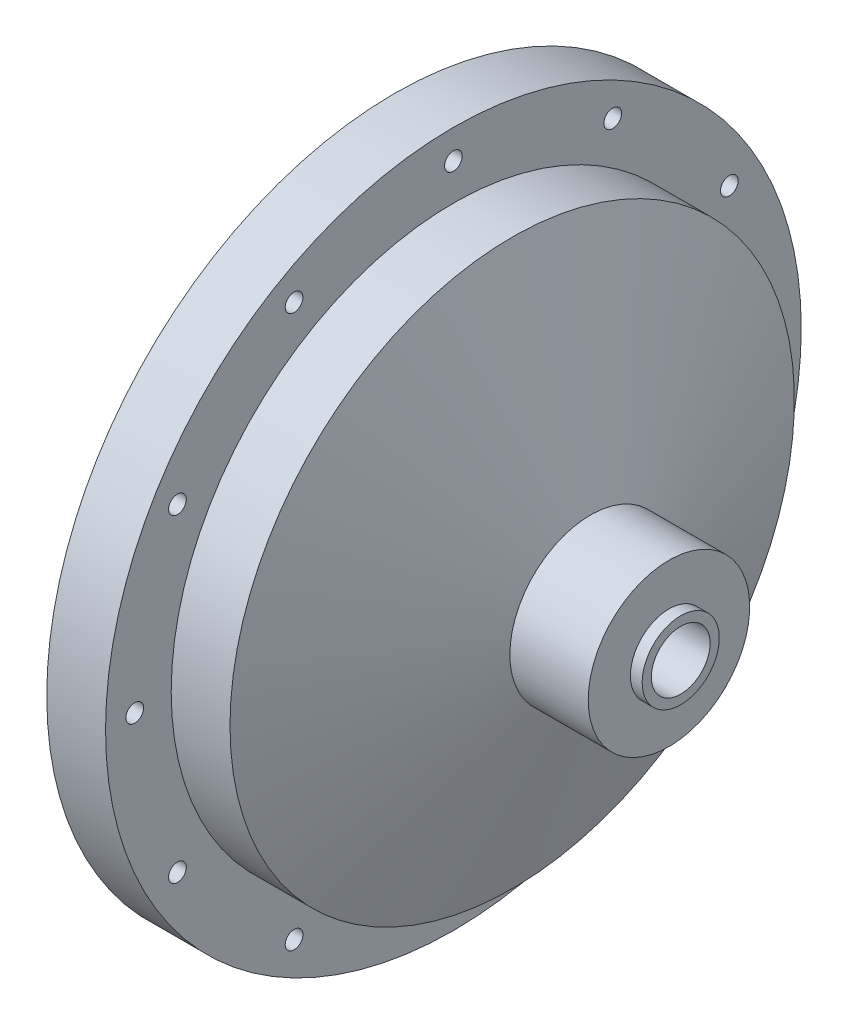
from build123d import *

# Parameters (mm, degrees)
SKETCH3_R                       = 4.7625
OXIDIZER_INLET_HOLE_DEPTH       = 93.199999203
FLANGE_HOLES_D                  = 2.8702
DOWEL_HOLES_D                   = 4.7625
DOWEL_HOLES_DEPTH               = 6.35
DOWEL_HOLES_TIP                 = 1.430799349
SKETCH12_R                      = 38.1
IMPINGING_PLATE_FLAT_CUT_DEPTH  = 3.81
SKETCH14_R                      = 38.1
SKETCH15_R                      = 38.1
SKETCH16_R                      = 28.575
SKETCH17_R                      = 4.7625
SKETCH21_R                      = 28.575
CUT_EXTRUDE1_DEPTH              = 9.525
INTERNAL_FILLET_R               = 3.175
EXTENDED_8_BC_COUNT             = 8
CHAMFER_FOR_IMPINGING_EDGE_SIZE = 0.127


with BuildPart() as part:
    # Sketch2 → Main Structure (revolve)
    with BuildSketch(Plane.XY, mode=Mode.PRIVATE) as main_structure_sk:
        Polygon((0, 0), (0, 56.35625), (9.525, 56.35625), (9.525, 45.72), (19.05, 45.72), (31.75, 13.081), (44.45, 13.081), (44.45, 6.2484), (46.355, 6.2484), (46.355, 0), align=None)
    revolve(main_structure_sk.sketch.rotate(Axis((0, 0, 0), (1, 0, 0)), 90), axis=Axis((0, 0, 0), (1, 0, 0)))

    # Sketch3 → Oxidizer Inlet Hole (cut, through all)
    with BuildSketch(Plane(origin=(46.355, 0, 0), x_dir=(0, 0, -1), z_dir=(1, 0, 0))):
        Circle(SKETCH3_R)
    extrude(amount=-OXIDIZER_INLET_HOLE_DEPTH, mode=Mode.SUBTRACT)

    # Flange Holes (through all)
    with Locations(Plane.ZY):
        with Locations((0, -51.6255), (-25.81275, -44.708994483), (-44.708994483, -25.81275), (-51.6255, 0), (-44.708994483, 25.81275), (-25.81275, 44.708994483), (0, 51.6255), (25.81275, 44.708994483), (44.708994483, 25.81275), (51.6255, 0), (44.708994483, -25.81275), (25.81275, -44.708994483)):
            Hole(FLANGE_HOLES_D / 2)

    # Dowel Holes
    with Locations(Plane.ZY):
        with Locations((49.866403745, -13.361662613), (-49.866403745, 13.361662613)):
            Hole(DOWEL_HOLES_D / 2, depth=DOWEL_HOLES_DEPTH)
            with Locations((0, 0, -(DOWEL_HOLES_DEPTH + DOWEL_HOLES_TIP / 2))):  # 118° drill point
                Cone(0, DOWEL_HOLES_D / 2, DOWEL_HOLES_TIP, mode=Mode.SUBTRACT)

    # Sketch12 → Impinging Plate Flat Cut (cut)
    with BuildSketch(Plane.ZY):
        Circle(SKETCH12_R)
    extrude(amount=-IMPINGING_PLATE_FLAT_CUT_DEPTH, mode=Mode.SUBTRACT)

    # Sketch14 → Impinging Plate Taper Cut section 0
    with BuildSketch(Plane.ZY.offset(-3.81)):
        Circle(SKETCH14_R)
    # Sketch15 → Impinging Plate Taper Cut section 1
    with BuildSketch(Plane.ZY.offset(-6.35)):
        Circle(SKETCH15_R)
    loft(mode=Mode.SUBTRACT)

    # Sketch16 → Internal Flow Path Loft Cut section 0
    with BuildSketch(Plane.ZY.offset(-15.875)):
        Circle(SKETCH16_R)
    # Sketch17 → Internal Flow Path Loft Cut section 1
    with BuildSketch(Plane.ZY.offset(-31.115)):
        Circle(SKETCH17_R)
    loft(mode=Mode.SUBTRACT)

    # Sketch21 → Cut-Extrude1 (cut)
    with BuildSketch(Plane.ZY.offset(-6.35)):
        Circle(SKETCH21_R)
    extrude(amount=-CUT_EXTRUDE1_DEPTH, mode=Mode.SUBTRACT)

    # Internal Fillet
    internal_fillet_edges = [part.edges().sort_by_distance(p)[0] for p in [
        (31.115, 4.7625, 0),
    ]]
    fillet(internal_fillet_edges, radius=INTERNAL_FILLET_R)

    # Sketch20 → 4-40 Tapped Holes (revolve, cut)
    with BuildSketch(Plane(origin=(6.35, 0, 33.3375), x_dir=(0, 0, 1), z_dir=(0, 1, 0))):
        Polygon((0, 0), (0, 3.854152758), (1.1303, 3.175), (1.1303, 0), align=None)
    f_4_40_tapped_holes = revolve(axis=Axis((0, 0, 33.3375), (1, 0, 0)), mode=Mode.SUBTRACT)

    # Extended 8 BC: 4-40 Tapped Holes ×8 about axis
    extended_8_bc_axis = Axis((0, 0, 0), (1, 0, 0))
    for i in range(1, EXTENDED_8_BC_COUNT):
        add(f_4_40_tapped_holes.rotate(extended_8_bc_axis, i * 360 / EXTENDED_8_BC_COUNT), mode=Mode.SUBTRACT)

    # Chamfer for Impinging Edge
    chamfer_for_impinging_edge_edges = [part.edges().sort_by_distance(p)[0] for p in [
        (6.35, 0, -38.1),
    ]]
    chamfer(chamfer_for_impinging_edge_edges, length=CHAMFER_FOR_IMPINGING_EDGE_SIZE)


solid = part.part
